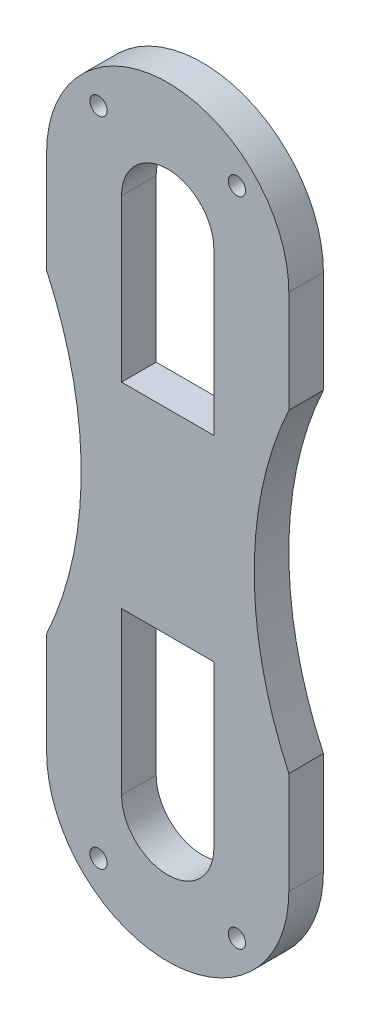
from build123d import *

# Parameters (mm, degrees)
SKETCH_1_R      = 0.75
EXTRUDE_1_DEPTH = 3


with BuildPart() as part:
    # 草图1 → 凸台-拉伸1 (new body)
    with BuildSketch(Plane.XY):
        with BuildLine():
            Line((-10.5, 22.5), (-10.5, 13.638181697))
            ThreePointArc((-10.5, 13.638181697), (-7.5, 0), (-10.5, -13.638181697))
            Line((-10.5, -13.638181697), (-10.5, -22.5))
            ThreePointArc((-10.5, -22.5), (0, -33), (10.5, -22.5))
            Line((10.5, -22.5), (10.5, -13.638181697))
            ThreePointArc((10.5, -13.638181697), (7.5, 0), (10.5, 13.638181697))
            Line((10.5, 13.638181697), (10.5, 22.5))
            ThreePointArc((10.5, 22.5), (0, 33), (-10.5, 22.5))
        make_face()
        with Locations((6, 28.25)):
            Circle(SKETCH_1_R, mode=Mode.SUBTRACT)
        with Locations((-6, 28.25)):
            Circle(SKETCH_1_R, mode=Mode.SUBTRACT)
        with Locations((6, -28.25)):
            Circle(SKETCH_1_R, mode=Mode.SUBTRACT)
        with Locations((-6, -28.25)):
            Circle(SKETCH_1_R, mode=Mode.SUBTRACT)
        with BuildLine():
            ThreePointArc((4, 22.500000371), (-3.71e-07, 26.5), (-4, 22.499999629))
            Line((-4, 22.499999629), (-4, 8.5))
            Line((-4, 8.5), (4, 8.5))
            Line((4, 8.5), (4, 22.500000371))
        make_face(mode=Mode.SUBTRACT)
        with BuildLine():
            Line((4, -22.500000371), (4, -8.5))
            Line((4, -8.5), (-4, -8.5))
            Line((-4, -8.5), (-4, -22.499999629))
            ThreePointArc((-4, -22.499999629), (-3.71e-07, -26.5), (4, -22.500000371))
        make_face(mode=Mode.SUBTRACT)
    extrude(amount=EXTRUDE_1_DEPTH)


solid = part.part
